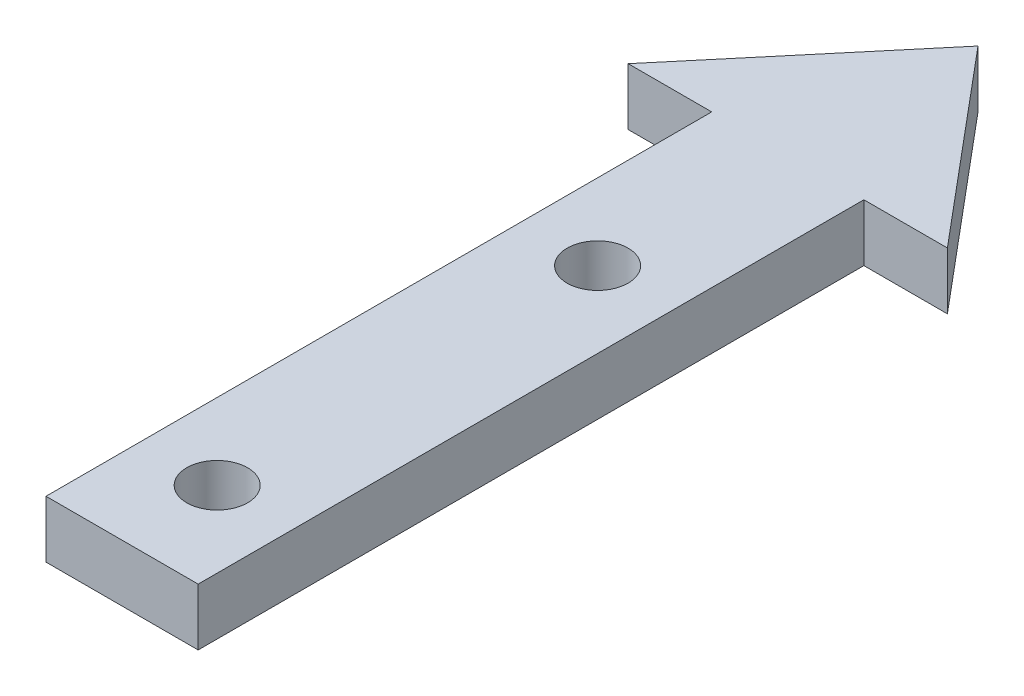
from build123d import *

# Parameters (mm, degrees)
SKETCH1_R           = 1.6
BOSS_EXTRUDE1_DEPTH = 3


with BuildPart() as part:
    # Sketch1 → Boss-Extrude1 (new body)
    with BuildSketch(Plane(origin=(0, 0, 0), x_dir=(1, 0, 0), z_dir=(0, 1, 0))):
        Polygon((8.390996312, 38.269741393), (0, 48.269741393), (-8.390996312, 38.269741393), (-4, 38.269741393), (-4, 3.269741393), (4, 3.269741393), (4, 38.269741393), align=None)
        with Locations((0, 28.269741393)):
            Circle(SKETCH1_R, mode=Mode.SUBTRACT)
        with Locations((0, 8.269741393)):
            Circle(SKETCH1_R, mode=Mode.SUBTRACT)
    extrude(amount=BOSS_EXTRUDE1_DEPTH)


solid = part.part
